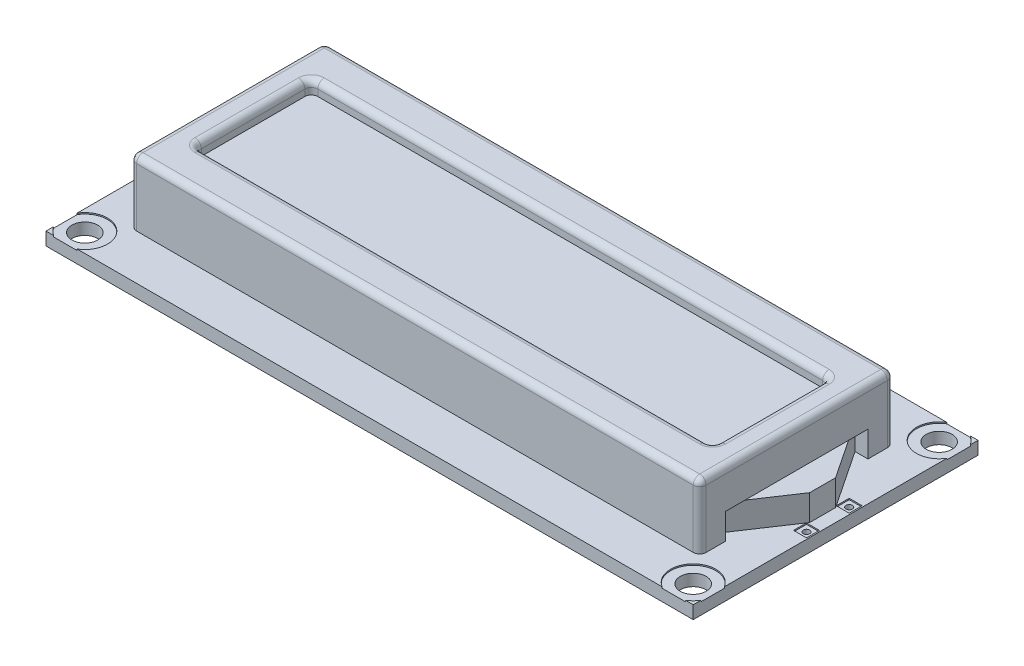
from build123d import *

# Parameters (mm, degrees)
SKETCH1_W           = 69.85
SKETCH1_H           = 23.8125
SKETCH1_W_2         = 79.375
SKETCH1_H_2         = 34.925
BOSS_EXTRUDE1_DEPTH = 1.5875
SKETCH1_3_W         = 69.85
SKETCH1_3_H         = 23.8125
BOSS_EXTRUDE2_DEPTH = 9.525
SKETCH2_R           = 1.5875
CUT_EXTRUDE1_DEPTH  = 2.5875
SKETCH3_W           = 63.5
SKETCH3_H           = 14.2875
CUT_EXTRUDE2_DEPTH  = 1.5875
FILLET1_R           = 0.79375
SKETCH4_R           = 2.778125
CUT_EXTRUDE4_DEPTH  = 0.15875
SKETCH5_W           = 3.175
SKETCH5_H           = 17.4625
CUT_EXTRUDE5_DEPTH  = 1.5875
SKETCH6_W           = 3.175
SKETCH6_H           = 3.175
SKETCH7_W           = 1.5875
SKETCH7_H           = 1.5875
CUT_EXTRUDE6_DEPTH  = 0.15875
SKETCH8_R           = 0.396875
CUT_EXTRUDE7_DEPTH  = 1.5875
SKETCH9_W           = 1.5875
SKETCH9_H           = 3.175
BOSS_EXTRUDE4_DEPTH = 0.79375
FILLET2_R           = 0.5953125
BOSS_EXTRUDE5_DEPTH = 2.38125
SKETCH11_W          = 0.79375
SKETCH11_H          = 0.817184428
BOSS_EXTRUDE6_DEPTH = 6.35


with BuildPart() as part:
    # Sketch1 → Boss-Extrude1 (new body)
    with BuildSketch(Plane(origin=(0, 0, 0), x_dir=(1, 0, 0), z_dir=(0, 1, 0))):
        Rectangle(SKETCH1_W, SKETCH1_H)
        Rectangle(SKETCH1_W_2, SKETCH1_H_2)
        Rectangle(SKETCH1_W, SKETCH1_H, mode=Mode.SUBTRACT)
    extrude(amount=BOSS_EXTRUDE1_DEPTH)

    # Sketch1_3 → Boss-Extrude2 (add)
    with BuildSketch(Plane(origin=(0, 0, 0), x_dir=(1, 0, 0), z_dir=(0, 1, 0))):
        Rectangle(SKETCH1_3_W, SKETCH1_3_H)
    extrude(amount=BOSS_EXTRUDE2_DEPTH)

    # Sketch2 → Cut-Extrude1 (cut, through all)
    with BuildSketch(Plane(origin=(0, 1.5875, 0), x_dir=(1, 0, 0), z_dir=(0, 1, 0))):
        with Locations((-37.30625, 15.08125)):
            Circle(SKETCH2_R)
        with Locations((-37.30625, -15.08125)):
            Circle(SKETCH2_R)
        with Locations((37.30625, -15.08125)):
            Circle(SKETCH2_R)
        with Locations((37.30625, 15.08125)):
            Circle(SKETCH2_R)
    extrude(amount=-CUT_EXTRUDE1_DEPTH, mode=Mode.SUBTRACT)

    # Sketch3 → Cut-Extrude2 (cut)
    with BuildSketch(Plane(origin=(0, 9.525, 0), x_dir=(1, 0, 0), z_dir=(0, 1, 0))):
        Rectangle(SKETCH3_W, SKETCH3_H)
    extrude(amount=-CUT_EXTRUDE2_DEPTH, mode=Mode.SUBTRACT)

    # Fillet1
    fillet1_edges = [part.edges().sort_by_distance(p)[0] for p in [
        (-34.925, 5.55625, 11.90625),
        (34.925, 5.55625, 11.90625),
        (34.925, 5.55625, -11.90625),
        (0, 9.525, -11.90625),
        (-34.925, 5.55625, -11.90625),
        (-34.925, 9.525, 0),
        (0, 9.525, 11.90625),
        (34.925, 9.525, 0),
        (-31.75, 8.73125, 7.14375),
        (-31.75, 8.73125, -7.14375),
        (31.75, 8.73125, -7.14375),
        (31.75, 8.73125, 7.14375),
        (-31.75, 9.525, 0),
        (0, 9.525, 7.14375),
        (31.75, 9.525, 0),
        (0, 9.525, -7.14375),
    ]]
    fillet(fillet1_edges, radius=FILLET1_R)

    # Sketch4 → Cut-Extrude4 (cut)
    with BuildSketch(Plane(origin=(0, 1.5875, 0), x_dir=(1, 0, 0), z_dir=(0, 1, 0))):
        with Locations((-37.30625, 15.08125)):
            Circle(SKETCH4_R)
        with Locations((-37.30625, -15.08125)):
            Circle(SKETCH4_R)
        with Locations((37.30625, -15.08125)):
            Circle(SKETCH4_R)
        with Locations((37.30625, 15.08125)):
            Circle(SKETCH4_R)
    extrude(amount=-CUT_EXTRUDE4_DEPTH, mode=Mode.SUBTRACT)

    # Sketch5 → Cut-Extrude5 (cut)
    with BuildSketch(Plane(origin=(34.925, 36.5125, 0), x_dir=(0, -1, 0), z_dir=(1, 0, 0))):
        with Locations((33.3375, 0)):
            Rectangle(SKETCH5_W, SKETCH5_H)
    extrude(amount=-CUT_EXTRUDE5_DEPTH, mode=Mode.SUBTRACT)

    # Sketch6 → section 0 of loft1
    with BuildSketch(Plane(origin=(38.1, 0, 0), x_dir=(0, 0, -1), z_dir=(1, 0, 0)), mode=Mode.PRIVATE) as loft1_s0:
        with Locations((0, 3.175)):
            Rectangle(SKETCH6_W, SKETCH6_H)
    # loft up to a face of the part (loft1)
    loft([loft1_s0.sketch, part.faces().sort_by_distance((33.3375, 3.175, 0))[0]])

    # Sketch7 → Cut-Extrude6 (cut)
    with BuildSketch(Plane(origin=(0, 1.5875, 0), x_dir=(1, 0, 0), z_dir=(0, 1, 0))):
        with Locations((38.735, 2.619375)):
            Rectangle(SKETCH7_W, SKETCH7_H)
        with Locations((38.735, -2.619375)):
            Rectangle(SKETCH7_W, SKETCH7_H)
    extrude(amount=-CUT_EXTRUDE6_DEPTH, mode=Mode.SUBTRACT)

    # Sketch8 → Cut-Extrude7 (cut)
    with BuildSketch(Plane(origin=(0, 1.42875, 0), x_dir=(1, 0, 0), z_dir=(0, 1, 0))):
        with Locations((38.735, 2.619375)):
            Circle(SKETCH8_R)
        with Locations((38.735, -2.619375)):
            Circle(SKETCH8_R)
    extrude(amount=-CUT_EXTRUDE7_DEPTH, mode=Mode.SUBTRACT)

    # Sketch9 → Boss-Extrude4 (add)
    with BuildSketch(Plane(origin=(0, 1.5875, 0), x_dir=(1, 0, 0), z_dir=(0, 1, 0))):
        with Locations((-32.54375, 15.71625)):
            Rectangle(SKETCH9_W, SKETCH9_H)
        with Locations((-30.16123, 15.71625)):
            Rectangle(SKETCH9_W, SKETCH9_H)
        with Locations((-27.77871, 15.71625)):
            Rectangle(SKETCH9_W, SKETCH9_H)
        with Locations((-25.39619, 15.71625)):
            Rectangle(SKETCH9_W, SKETCH9_H)
        with Locations((-23.01367, 15.71625)):
            Rectangle(SKETCH9_W, SKETCH9_H)
        with Locations((-20.63115, 15.71625)):
            Rectangle(SKETCH9_W, SKETCH9_H)
        with Locations((-18.24863, 15.71625)):
            Rectangle(SKETCH9_W, SKETCH9_H)
        with Locations((-15.86611, 15.71625)):
            Rectangle(SKETCH9_W, SKETCH9_H)
        with Locations((-13.48359, 15.71625)):
            Rectangle(SKETCH9_W, SKETCH9_H)
        with Locations((-11.10107, 15.71625)):
            Rectangle(SKETCH9_W, SKETCH9_H)
        with Locations((-8.71855, 15.71625)):
            Rectangle(SKETCH9_W, SKETCH9_H)
        with Locations((-6.33603, 15.71625)):
            Rectangle(SKETCH9_W, SKETCH9_H)
        with Locations((-3.95351, 15.71625)):
            Rectangle(SKETCH9_W, SKETCH9_H)
        with Locations((-1.57099, 15.71625)):
            Rectangle(SKETCH9_W, SKETCH9_H)
        with Locations((0.81153, 15.71625)):
            Rectangle(SKETCH9_W, SKETCH9_H)
        with Locations((3.19405, 15.71625)):
            Rectangle(SKETCH9_W, SKETCH9_H)
    extrude(amount=BOSS_EXTRUDE4_DEPTH)

    # Fillet2
    fillet2_edges = [part.edges().sort_by_distance(p)[0] for p in [
        (-33.3375, 2.38125, -15.71625),
        (-32.54375, 2.38125, -14.12875),
        (-31.75, 2.38125, -15.71625),
        (-32.54375, 2.38125, -17.30375),
        (-30.16123, 2.38125, -17.30375),
        (-30.95498, 2.38125, -15.71625),
        (-30.16123, 2.38125, -14.12875),
        (-29.36748, 2.38125, -15.71625),
        (-27.77871, 2.38125, -17.30375),
        (-28.57246, 2.38125, -15.71625),
        (-27.77871, 2.38125, -14.12875),
        (-26.98496, 2.38125, -15.71625),
        (-25.39619, 2.38125, -17.30375),
        (-26.18994, 2.38125, -15.71625),
        (-25.39619, 2.38125, -14.12875),
        (-24.60244, 2.38125, -15.71625),
        (-23.01367, 2.38125, -17.30375),
        (-23.80742, 2.38125, -15.71625),
        (-23.01367, 2.38125, -14.12875),
        (-22.21992, 2.38125, -15.71625),
        (-20.63115, 2.38125, -17.30375),
        (-21.4249, 2.38125, -15.71625),
        (-20.63115, 2.38125, -14.12875),
        (-19.8374, 2.38125, -15.71625),
        (-18.24863, 2.38125, -17.30375),
        (-19.04238, 2.38125, -15.71625),
        (-18.24863, 2.38125, -14.12875),
        (-17.45488, 2.38125, -15.71625),
        (-15.86611, 2.38125, -17.30375),
        (-16.65986, 2.38125, -15.71625),
        (-15.86611, 2.38125, -14.12875),
        (-15.07236, 2.38125, -15.71625),
        (-13.48359, 2.38125, -17.30375),
        (-14.27734, 2.38125, -15.71625),
        (-13.48359, 2.38125, -14.12875),
        (-12.68984, 2.38125, -15.71625),
        (-11.10107, 2.38125, -17.30375),
        (-11.89482, 2.38125, -15.71625),
        (-11.10107, 2.38125, -14.12875),
        (-10.30732, 2.38125, -15.71625),
        (-8.71855, 2.38125, -17.30375),
        (-9.5123, 2.38125, -15.71625),
        (-8.71855, 2.38125, -14.12875),
        (-7.9248, 2.38125, -15.71625),
        (-6.33603, 2.38125, -17.30375),
        (-7.12978, 2.38125, -15.71625),
        (-6.33603, 2.38125, -14.12875),
        (-5.54228, 2.38125, -15.71625),
        (-3.95351, 2.38125, -17.30375),
        (-4.74726, 2.38125, -15.71625),
        (-3.95351, 2.38125, -14.12875),
        (-3.15976, 2.38125, -15.71625),
        (-1.57099, 2.38125, -17.30375),
        (-2.36474, 2.38125, -15.71625),
        (-1.57099, 2.38125, -14.12875),
        (-0.77724, 2.38125, -15.71625),
        (0.81153, 2.38125, -17.30375),
        (0.01778, 2.38125, -15.71625),
        (0.81153, 2.38125, -14.12875),
        (1.60528, 2.38125, -15.71625),
        (3.19405, 2.38125, -17.30375),
        (2.4003, 2.38125, -15.71625),
        (3.19405, 2.38125, -14.12875),
        (3.9878, 2.38125, -15.71625),
    ]]
    fillet(fillet2_edges, radius=FILLET2_R)

    # Sketch10 → Boss-Extrude5 (add)
    with BuildSketch(Plane.XZ):
        with BuildLine():
            Line((-33.02, -17.30375), (-31.27375, -17.30375))
            ThreePointArc((-31.27375, -17.30375), (-31.049243597, -17.210756403), (-30.95625, -16.98625))
            Line((-30.95625, -16.98625), (-30.95625, -15.24))
            ThreePointArc((-30.95625, -15.24), (-31.049243597, -15.015493597), (-31.27375, -14.9225))
            Line((-31.27375, -14.9225), (-33.02, -14.9225))
            ThreePointArc((-33.02, -14.9225), (-33.244506403, -15.015493597), (-33.3375, -15.24))
            Line((-33.3375, -15.24), (-33.3375, -16.98625))
            ThreePointArc((-33.3375, -16.98625), (-33.244506403, -17.210756403), (-33.02, -17.30375))
        make_face()
        with BuildLine():
            Line((-30.63748, -14.9225), (-28.89123, -14.9225))
            ThreePointArc((-28.89123, -14.9225), (-28.666723597, -15.015493597), (-28.57373, -15.24))
            Line((-28.57373, -15.24), (-28.57373, -16.98625))
            ThreePointArc((-28.57373, -16.98625), (-28.666723597, -17.210756403), (-28.89123, -17.30375))
            Line((-28.89123, -17.30375), (-30.63748, -17.30375))
            ThreePointArc((-30.63748, -17.30375), (-30.861986403, -17.210756403), (-30.95498, -16.98625))
            Line((-30.95498, -16.98625), (-30.95498, -15.24))
            ThreePointArc((-30.95498, -15.24), (-30.861986403, -15.015493597), (-30.63748, -14.9225))
        make_face()
        with BuildLine():
            Line((-28.25496, -14.9225), (-26.50871, -14.9225))
            ThreePointArc((-26.50871, -14.9225), (-26.284203597, -15.015493597), (-26.19121, -15.24))
            Line((-26.19121, -15.24), (-26.19121, -16.98625))
            ThreePointArc((-26.19121, -16.98625), (-26.284203597, -17.210756403), (-26.50871, -17.30375))
            Line((-26.50871, -17.30375), (-28.25496, -17.30375))
            ThreePointArc((-28.25496, -17.30375), (-28.479466403, -17.210756403), (-28.57246, -16.98625))
            Line((-28.57246, -16.98625), (-28.57246, -15.24))
            ThreePointArc((-28.57246, -15.24), (-28.479466403, -15.015493597), (-28.25496, -14.9225))
        make_face()
        with BuildLine():
            Line((-25.87244, -14.9225), (-24.12619, -14.9225))
            ThreePointArc((-24.12619, -14.9225), (-23.901683597, -15.015493597), (-23.80869, -15.24))
            Line((-23.80869, -15.24), (-23.80869, -16.98625))
            ThreePointArc((-23.80869, -16.98625), (-23.901683597, -17.210756403), (-24.12619, -17.30375))
            Line((-24.12619, -17.30375), (-25.87244, -17.30375))
            ThreePointArc((-25.87244, -17.30375), (-26.096946403, -17.210756403), (-26.18994, -16.98625))
            Line((-26.18994, -16.98625), (-26.18994, -15.24))
            ThreePointArc((-26.18994, -15.24), (-26.096946403, -15.015493597), (-25.87244, -14.9225))
        make_face()
        with BuildLine():
            Line((-23.48992, -14.9225), (-21.74367, -14.9225))
            ThreePointArc((-21.74367, -14.9225), (-21.519163597, -15.015493597), (-21.42617, -15.24))
            Line((-21.42617, -15.24), (-21.42617, -16.98625))
            ThreePointArc((-21.42617, -16.98625), (-21.519163597, -17.210756403), (-21.74367, -17.30375))
            Line((-21.74367, -17.30375), (-23.48992, -17.30375))
            ThreePointArc((-23.48992, -17.30375), (-23.714426403, -17.210756403), (-23.80742, -16.98625))
            Line((-23.80742, -16.98625), (-23.80742, -15.24))
            ThreePointArc((-23.80742, -15.24), (-23.714426403, -15.015493597), (-23.48992, -14.9225))
        make_face()
        with BuildLine():
            Line((-21.1074, -14.9225), (-19.36115, -14.9225))
            ThreePointArc((-19.36115, -14.9225), (-19.136643597, -15.015493597), (-19.04365, -15.24))
            Line((-19.04365, -15.24), (-19.04365, -16.98625))
            ThreePointArc((-19.04365, -16.98625), (-19.136643597, -17.210756403), (-19.36115, -17.30375))
            Line((-19.36115, -17.30375), (-21.1074, -17.30375))
            ThreePointArc((-21.1074, -17.30375), (-21.331906403, -17.210756403), (-21.4249, -16.98625))
            Line((-21.4249, -16.98625), (-21.4249, -15.24))
            ThreePointArc((-21.4249, -15.24), (-21.331906403, -15.015493597), (-21.1074, -14.9225))
        make_face()
        with BuildLine():
            Line((-18.72488, -14.9225), (-16.97863, -14.9225))
            ThreePointArc((-16.97863, -14.9225), (-16.754123597, -15.015493597), (-16.66113, -15.24))
            Line((-16.66113, -15.24), (-16.66113, -16.98625))
            ThreePointArc((-16.66113, -16.98625), (-16.754123597, -17.210756403), (-16.97863, -17.30375))
            Line((-16.97863, -17.30375), (-18.72488, -17.30375))
            ThreePointArc((-18.72488, -17.30375), (-18.949386403, -17.210756403), (-19.04238, -16.98625))
            Line((-19.04238, -16.98625), (-19.04238, -15.24))
            ThreePointArc((-19.04238, -15.24), (-18.949386403, -15.015493597), (-18.72488, -14.9225))
        make_face()
        with BuildLine():
            Line((-16.34236, -14.9225), (-14.59611, -14.9225))
            ThreePointArc((-14.59611, -14.9225), (-14.371603597, -15.015493597), (-14.27861, -15.24))
            Line((-14.27861, -15.24), (-14.27861, -16.98625))
            ThreePointArc((-14.27861, -16.98625), (-14.371603597, -17.210756403), (-14.59611, -17.30375))
            Line((-14.59611, -17.30375), (-16.34236, -17.30375))
            ThreePointArc((-16.34236, -17.30375), (-16.566866403, -17.210756403), (-16.65986, -16.98625))
            Line((-16.65986, -16.98625), (-16.65986, -15.24))
            ThreePointArc((-16.65986, -15.24), (-16.566866403, -15.015493597), (-16.34236, -14.9225))
        make_face()
        with BuildLine():
            Line((-13.95984, -14.9225), (-12.21359, -14.9225))
            ThreePointArc((-12.21359, -14.9225), (-11.989083597, -15.015493597), (-11.89609, -15.24))
            Line((-11.89609, -15.24), (-11.89609, -16.98625))
            ThreePointArc((-11.89609, -16.98625), (-11.989083597, -17.210756403), (-12.21359, -17.30375))
            Line((-12.21359, -17.30375), (-13.95984, -17.30375))
            ThreePointArc((-13.95984, -17.30375), (-14.184346403, -17.210756403), (-14.27734, -16.98625))
            Line((-14.27734, -16.98625), (-14.27734, -15.24))
            ThreePointArc((-14.27734, -15.24), (-14.184346403, -15.015493597), (-13.95984, -14.9225))
        make_face()
        with BuildLine():
            Line((-11.57732, -14.9225), (-9.83107, -14.9225))
            ThreePointArc((-9.83107, -14.9225), (-9.606563597, -15.015493597), (-9.51357, -15.24))
            Line((-9.51357, -15.24), (-9.51357, -16.98625))
            ThreePointArc((-9.51357, -16.98625), (-9.606563597, -17.210756403), (-9.83107, -17.30375))
            Line((-9.83107, -17.30375), (-11.57732, -17.30375))
            ThreePointArc((-11.57732, -17.30375), (-11.801826403, -17.210756403), (-11.89482, -16.98625))
            Line((-11.89482, -16.98625), (-11.89482, -15.24))
            ThreePointArc((-11.89482, -15.24), (-11.801826403, -15.015493597), (-11.57732, -14.9225))
        make_face()
        with BuildLine():
            Line((-9.1948, -14.9225), (-7.44855, -14.9225))
            ThreePointArc((-7.44855, -14.9225), (-7.224043597, -15.015493597), (-7.13105, -15.24))
            Line((-7.13105, -15.24), (-7.13105, -16.98625))
            ThreePointArc((-7.13105, -16.98625), (-7.224043597, -17.210756403), (-7.44855, -17.30375))
            Line((-7.44855, -17.30375), (-9.1948, -17.30375))
            ThreePointArc((-9.1948, -17.30375), (-9.419306403, -17.210756403), (-9.5123, -16.98625))
            Line((-9.5123, -16.98625), (-9.5123, -15.24))
            ThreePointArc((-9.5123, -15.24), (-9.419306403, -15.015493597), (-9.1948, -14.9225))
        make_face()
        with BuildLine():
            Line((-6.81228, -14.9225), (-5.06603, -14.9225))
            ThreePointArc((-5.06603, -14.9225), (-4.841523597, -15.015493597), (-4.74853, -15.24))
            Line((-4.74853, -15.24), (-4.74853, -16.98625))
            ThreePointArc((-4.74853, -16.98625), (-4.841523597, -17.210756403), (-5.06603, -17.30375))
            Line((-5.06603, -17.30375), (-6.81228, -17.30375))
            ThreePointArc((-6.81228, -17.30375), (-7.036786403, -17.210756403), (-7.12978, -16.98625))
            Line((-7.12978, -16.98625), (-7.12978, -15.24))
            ThreePointArc((-7.12978, -15.24), (-7.036786403, -15.015493597), (-6.81228, -14.9225))
        make_face()
        with BuildLine():
            Line((-4.42976, -14.9225), (-2.68351, -14.9225))
            ThreePointArc((-2.68351, -14.9225), (-2.459003597, -15.015493597), (-2.36601, -15.24))
            Line((-2.36601, -15.24), (-2.36601, -16.98625))
            ThreePointArc((-2.36601, -16.98625), (-2.459003597, -17.210756403), (-2.68351, -17.30375))
            Line((-2.68351, -17.30375), (-4.42976, -17.30375))
            ThreePointArc((-4.42976, -17.30375), (-4.654266403, -17.210756403), (-4.74726, -16.98625))
            Line((-4.74726, -16.98625), (-4.74726, -15.24))
            ThreePointArc((-4.74726, -15.24), (-4.654266403, -15.015493597), (-4.42976, -14.9225))
        make_face()
        with BuildLine():
            Line((-2.04724, -14.9225), (-0.30099, -14.9225))
            ThreePointArc((-0.30099, -14.9225), (-0.076483597, -15.015493597), (0.01651, -15.24))
            Line((0.01651, -15.24), (0.01651, -16.98625))
            ThreePointArc((0.01651, -16.98625), (-0.076483597, -17.210756403), (-0.30099, -17.30375))
            Line((-0.30099, -17.30375), (-2.04724, -17.30375))
            ThreePointArc((-2.04724, -17.30375), (-2.271746403, -17.210756403), (-2.36474, -16.98625))
            Line((-2.36474, -16.98625), (-2.36474, -15.24))
            ThreePointArc((-2.36474, -15.24), (-2.271746403, -15.015493597), (-2.04724, -14.9225))
        make_face()
        with BuildLine():
            Line((0.33528, -14.9225), (2.08153, -14.9225))
            ThreePointArc((2.08153, -14.9225), (2.306036403, -15.015493597), (2.39903, -15.24))
            Line((2.39903, -15.24), (2.39903, -16.98625))
            ThreePointArc((2.39903, -16.98625), (2.306036403, -17.210756403), (2.08153, -17.30375))
            Line((2.08153, -17.30375), (0.33528, -17.30375))
            ThreePointArc((0.33528, -17.30375), (0.110773597, -17.210756403), (0.01778, -16.98625))
            Line((0.01778, -16.98625), (0.01778, -15.24))
            ThreePointArc((0.01778, -15.24), (0.110773597, -15.015493597), (0.33528, -14.9225))
        make_face()
        with BuildLine():
            Line((2.7178, -14.9225), (4.46405, -14.9225))
            ThreePointArc((4.46405, -14.9225), (4.688556403, -15.015493597), (4.78155, -15.24))
            Line((4.78155, -15.24), (4.78155, -16.98625))
            ThreePointArc((4.78155, -16.98625), (4.688556403, -17.210756403), (4.46405, -17.30375))
            Line((4.46405, -17.30375), (2.7178, -17.30375))
            ThreePointArc((2.7178, -17.30375), (2.493293597, -17.210756403), (2.4003, -16.98625))
            Line((2.4003, -16.98625), (2.4003, -15.24))
            ThreePointArc((2.4003, -15.24), (2.493293597, -15.015493597), (2.7178, -14.9225))
        make_face()
    extrude(amount=BOSS_EXTRUDE5_DEPTH)

    # Sketch11 → Boss-Extrude6 (add)
    with BuildSketch(Plane.XZ.offset(2.38125)):
        with Locations((1.208405, -16.113125)):
            Rectangle(SKETCH11_W, SKETCH11_H)
        with Locations((3.590925, -16.113125)):
            Rectangle(SKETCH11_W, SKETCH11_H)
        with Locations((-1.174115, -16.113125)):
            Rectangle(SKETCH11_W, SKETCH11_H)
        with Locations((-3.556635, -16.113125)):
            Rectangle(SKETCH11_W, SKETCH11_H)
        with Locations((-5.939155, -16.113125)):
            Rectangle(SKETCH11_W, SKETCH11_H)
        with Locations((-8.321675, -16.113125)):
            Rectangle(SKETCH11_W, SKETCH11_H)
        with Locations((-10.704195, -16.113125)):
            Rectangle(SKETCH11_W, SKETCH11_H)
        with Locations((-13.086715, -16.113125)):
            Rectangle(SKETCH11_W, SKETCH11_H)
        with Locations((-15.469235, -16.113125)):
            Rectangle(SKETCH11_W, SKETCH11_H)
        with Locations((-17.851755, -16.113125)):
            Rectangle(SKETCH11_W, SKETCH11_H)
        with Locations((-20.234275, -16.113125)):
            Rectangle(SKETCH11_W, SKETCH11_H)
        with Locations((-22.616795, -16.113125)):
            Rectangle(SKETCH11_W, SKETCH11_H)
        with Locations((-24.999315, -16.113125)):
            Rectangle(SKETCH11_W, SKETCH11_H)
        with Locations((-27.381835, -16.113125)):
            Rectangle(SKETCH11_W, SKETCH11_H)
        with Locations((-29.764355, -16.113125)):
            Rectangle(SKETCH11_W, SKETCH11_H)
        with Locations((-32.146875, -16.113125)):
            Rectangle(SKETCH11_W, SKETCH11_H)
    extrude(amount=BOSS_EXTRUDE6_DEPTH)


solid = part.part
